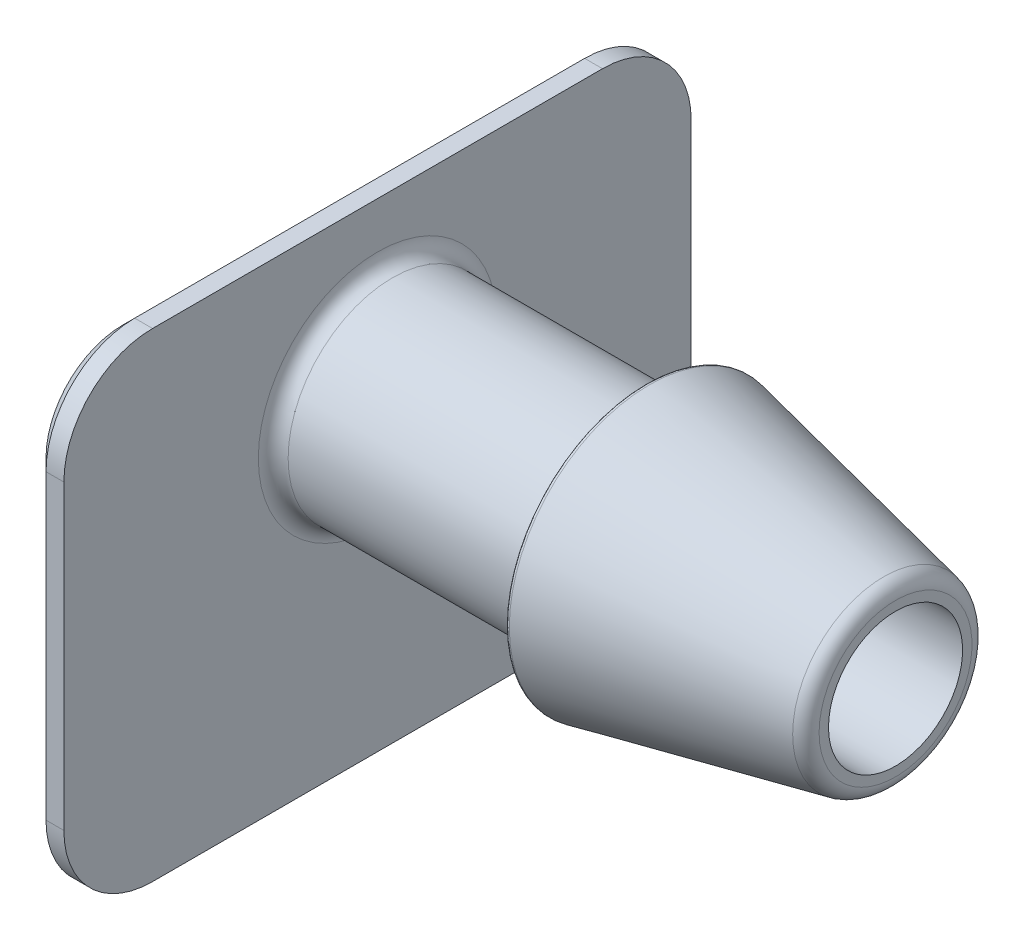
from build123d import *

# Parameters (mm, degrees)
SKETCH20_R          = 2.350664171
BOSS_EXTRUDE1_DEPTH = 0.5
CHAMFER1_SIZE       = 0.2


with BuildPart() as part:
    # Sketch19 → Revolve1 (revolve)
    with BuildSketch(Plane.XY, mode=Mode.PRIVATE) as revolve1_sk:
        with BuildLine():
            Line((1.80625, 1.491762035), (2.813920411, 1.125))
            Line((2.813920411, 1.125), (10.99725, 1.125))
            Line((10.99725, 1.125), (10.99725, 1.28276631))
            ThreePointArc((10.99725, 1.28276631), (10.941275199, 1.440418529), (10.798416223, 1.527474335))
            Line((10.798416223, 1.527474335), (6.866483245, 2.349605776))
            ThreePointArc((6.866483245, 2.349605776), (6.824719556, 2.339469211), (6.80625, 2.300664171))
            Line((6.80625, 2.300664171), (6.80625, 2))
            ThreePointArc((6.80625, 2), (6.733026695, 1.823223305), (6.55625, 1.75))
            Line((6.55625, 1.75), (2.55625, 1.75))
            ThreePointArc((2.55625, 1.75), (2.379473305, 1.823223305), (2.30625, 2))
            Line((2.30625, 2), (2.30625, 2.75))
            Line((2.30625, 2.75), (1.80625, 2.75))
            Line((1.80625, 2.75), (1.80625, 1.491762035))
        make_face()
    revolve(revolve1_sk.sketch.rotate(Axis((0, 0, 0), (1, 0, 0)), 90), axis=Axis((0, 0, 0), (1, 0, 0)))  # turned: the seam where the file's is

    # Sketch20 → Boss-Extrude1 (add)
    with BuildSketch(Plane(origin=(2.30625, 0, 0), x_dir=(0, 0, -1), z_dir=(1, 0, 0))):
        with BuildLine():
            Line((-3.7747, 2.775), (3.7747, 2.775))
            ThreePointArc((3.7747, 2.775), (4.826521337, 2.339321337), (5.2622, 1.2875))
            Line((5.2622, 1.2875), (5.2622, -3.7747))
            ThreePointArc((5.2622, -3.7747), (4.826521337, -4.826521337), (3.7747, -5.2622))
            Line((3.7747, -5.2622), (-3.7747, -5.2622))
            ThreePointArc((-3.7747, -5.2622), (-4.826521337, -4.826521337), (-5.2622, -3.7747))
            Line((-5.2622, -3.7747), (-5.2622, 1.2875))
            ThreePointArc((-5.2622, 1.2875), (-4.826521337, 2.339321337), (-3.7747, 2.775))
        make_face()
        Circle(SKETCH20_R, mode=Mode.SUBTRACT)
    extrude(amount=-BOSS_EXTRUDE1_DEPTH)

    # Chamfer1
    chamfer1_edges = [part.edges().sort_by_distance(p)[0] for p in [
        (1.80625, 2.339321337, -4.826521337),
        (1.80625, -1.2436, -5.2622),
        (1.80625, -4.826521337, -4.826521337),
        (1.80625, -5.2622, 0),
        (1.80625, -4.826521337, 4.826521337),
        (1.80625, -1.2436, 5.2622),
        (1.80625, 2.339321337, 4.826521337),
        (1.80625, 2.775, 0),
    ]]
    chamfer(chamfer1_edges, length=CHAMFER1_SIZE)


solid = part.part
